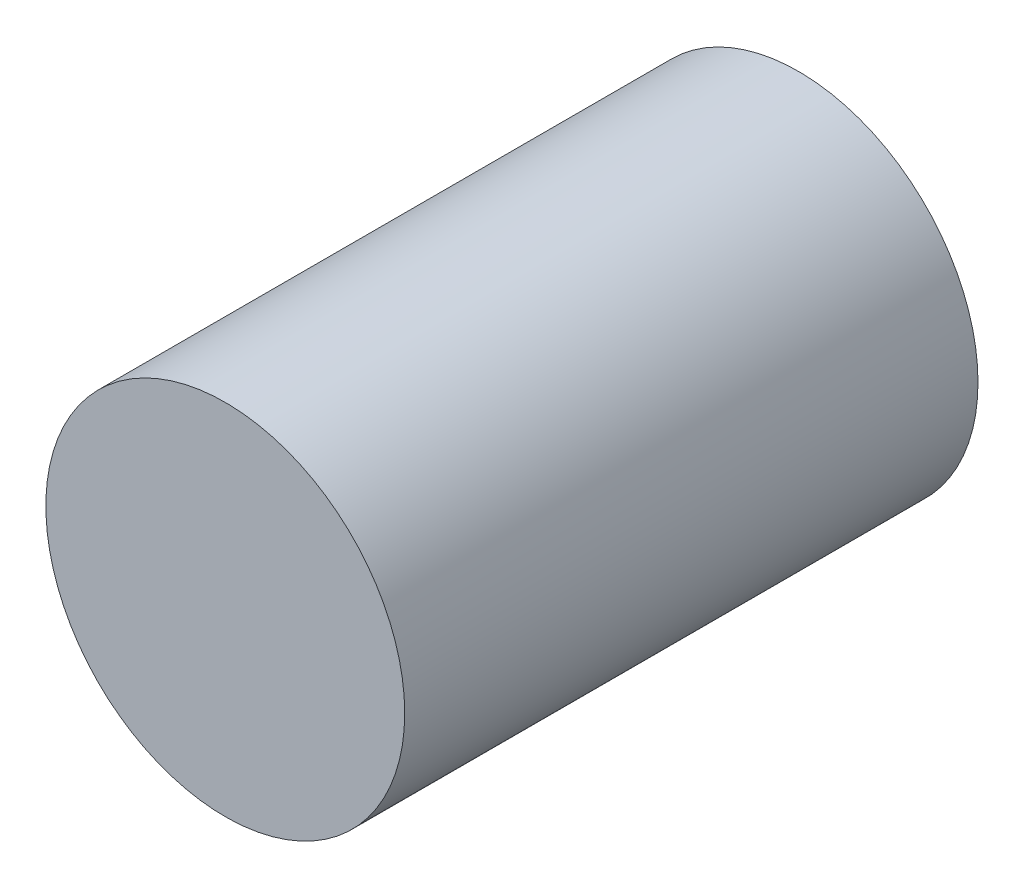
from build123d import *

# Parameters (mm, degrees)
SKETCH1_R           = 15.9
BOSS_EXTRUDE1_DEPTH = 50.8


with BuildPart() as part:
    # Sketch1 → Boss-Extrude1 (new body)
    with BuildSketch(Plane.XY):
        Circle(SKETCH1_R)
    extrude(amount=BOSS_EXTRUDE1_DEPTH)


solid = part.part
